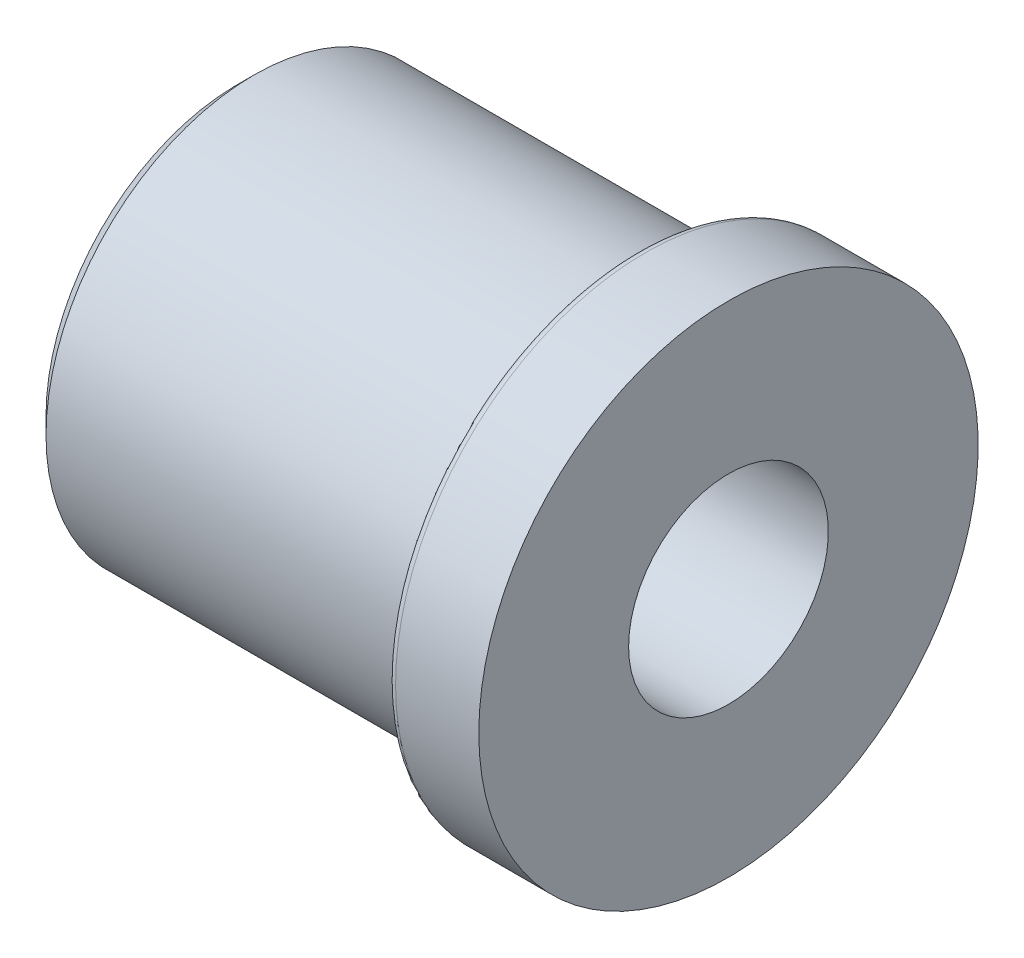
from build123d import *


with BuildPart() as part:
    # Esquisse1 → Révolution1 (revolve)
    with BuildSketch(Plane.XY, mode=Mode.PRIVATE) as r_volution1_sk:
        with BuildLine():
            Line((0, 6), (29.5, 6))
            Line((29.5, 6), (29.5, 15))
            Line((29.5, 15), (24.5, 15))
            ThreePointArc((24.5, 15), (24.146446609, 14.853553391), (24, 14.5))
            Line((24, 14.5), (24, 12.5))
            Line((24, 12.5), (1, 12.5))
            Line((1, 12.5), (0, 11.5))
            Line((0, 11.5), (0, 6))
        make_face()
    revolve(r_volution1_sk.sketch.rotate(Axis((0, 0, 0), (1, 0, 0)), 90), axis=Axis((0, 0, 0), (1, 0, 0)))  # turned: the seam where the file's is


solid = part.part
